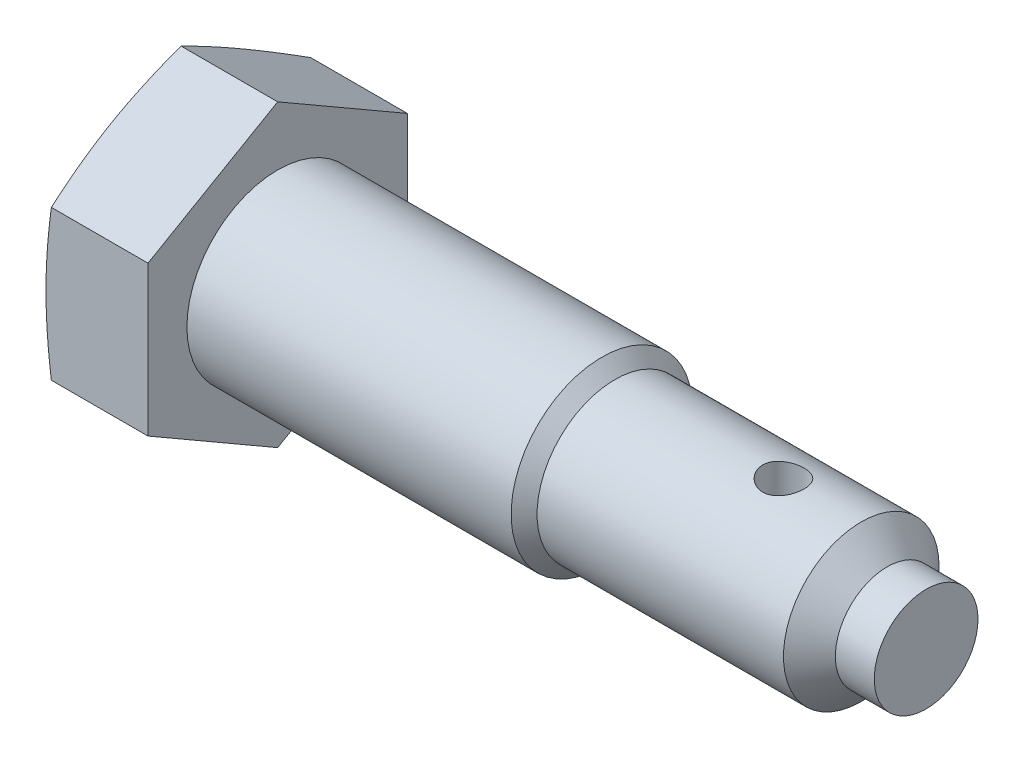
from build123d import *

# Parameters (mm, degrees)
BASEHEAD_DEPTH  = 4
SKE2_R          = 0.8
HOLE_DEPTH      = 6.773502692
HOLE_DEPTH_BACK = 6.773502692


with BuildPart() as part:
    # BodySke → BaseBody (revolve)
    with BuildSketch(Plane.XY):
        Polygon((0, 0), (0, 3.5), (12.5, 3.5), (13, 3), (22.5, 3), (23.5, 2), (25, 2), (25, 0), align=None)
    revolve(axis=Axis((0, 0, 0), (-1, 0, 0)))

    # Ske → BaseHead (add)
    with BuildSketch(Plane.ZY):
        Polygon((0, 5.773502692), (-5, 2.886751346), (-5, -2.886751346), (0, -5.773502692), (5, -2.886751346), (5, 2.886751346), align=None)
    extrude(amount=BASEHEAD_DEPTH)

    # Ske1 → HeadFillet (revolve, cut)
    with BuildSketch(Plane.XY):
        Polygon((-4, 5.773502692), (-3.72575328, 5.773502692), (-4, 4.75), align=None)
    revolve(axis=Axis((0, 0, 0), (-1, 0, 0)), mode=Mode.SUBTRACT)

    # Ske2 → Hole (cut, two sides)
    with BuildSketch(Plane(origin=(0, 0, 0), x_dir=(1, 0, 0), z_dir=(0, 1, 0))) as hole_sk:
        with Locations((19.5, 0)):
            Circle(SKE2_R)
    extrude(amount=HOLE_DEPTH, mode=Mode.SUBTRACT)
    extrude(hole_sk.sketch, amount=-HOLE_DEPTH_BACK, mode=Mode.SUBTRACT)


solid = part.part
